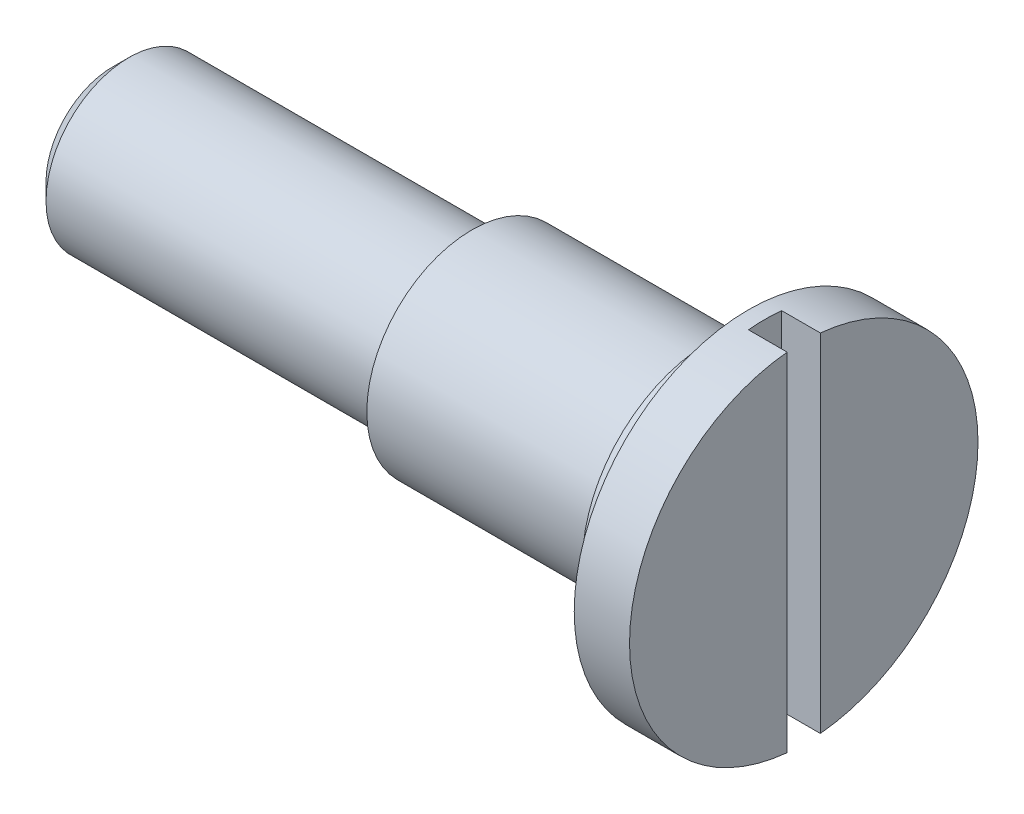
from build123d import *

# Parameters (mm, degrees)
CUT_EXTRUDE_1_DEPTH      = 4.15
CUT_EXTRUDE_1_DEPTH_BACK = 4.15


with BuildPart() as part:
    # Эскиз1 → Повернуть1 (revolve)
    with BuildSketch(Plane(origin=(0, 0, 0), x_dir=(1, 0, 0), z_dir=(0, 1, 0))):
        Polygon((0, 0), (0, 1.2), (0.3, 1.5), (6.5, 1.5), (6.5, 1.9), (10.8, 1.9), (10.8, 2.3), (11.5, 2.3), (11.5, 3.15), (12.5, 3.15), (12.5, 0), align=None)
    revolve(axis=Axis((-1.842251792, 0, 0), (1, 0, 0)))

    # Эскиз2 → Вырез-Вытянуть1 (cut, two sides)
    with BuildSketch(Plane(origin=(0, 0, 0), x_dir=(1, 0, 0), z_dir=(0, 1, 0))) as cut_extrude_1_sk:
        Polygon((48.434725755, 0.3), (12.5, 0.3), (11.8, 0.3), (11.8, -0.3), (12.5, -0.3), (48.434725755, -0.3), (120.304177266, -0.3), (120.304177266, 0.3), align=None)
    extrude(amount=CUT_EXTRUDE_1_DEPTH, mode=Mode.SUBTRACT)
    extrude(cut_extrude_1_sk.sketch, amount=-CUT_EXTRUDE_1_DEPTH_BACK, mode=Mode.SUBTRACT)


solid = part.part
